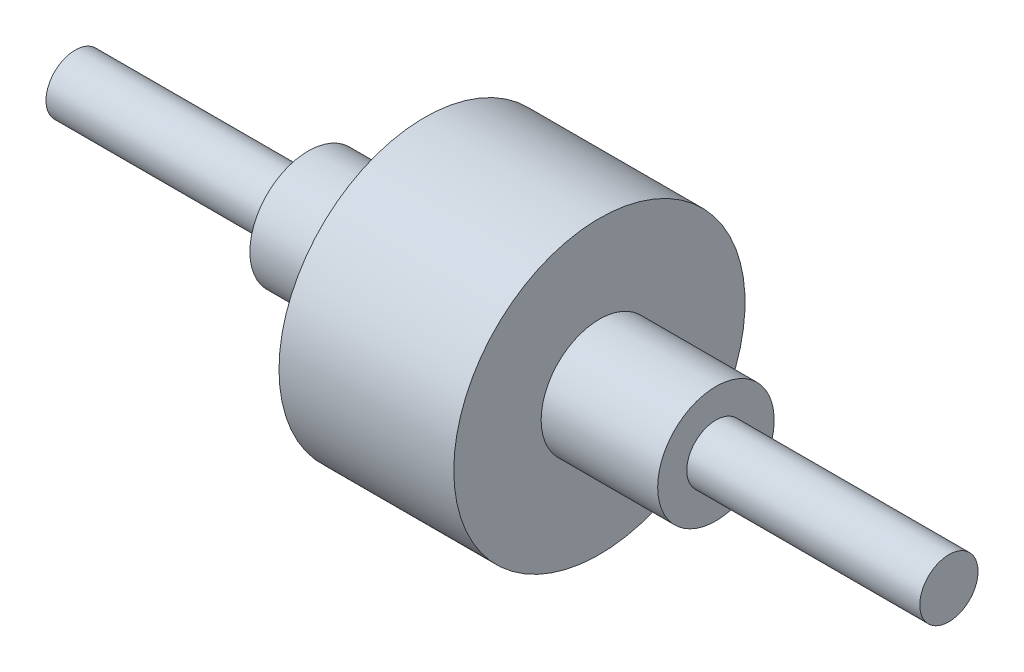
from build123d import *


with BuildPart() as part:
    # Croquis1 → Revolución5 (revolve)
    with BuildSketch(Plane.XY):
        Polygon((150, 0), (150, 10), (70, 10), (70, 20), (30, 20), (30, 50), (-30, 50), (-30, 20), (-70, 20), (-70, 10), (-150, 10), (-150, 0), align=None)
    revolve(axis=Axis((-150, 0, 0), (1, 0, 0)))


solid = part.part
